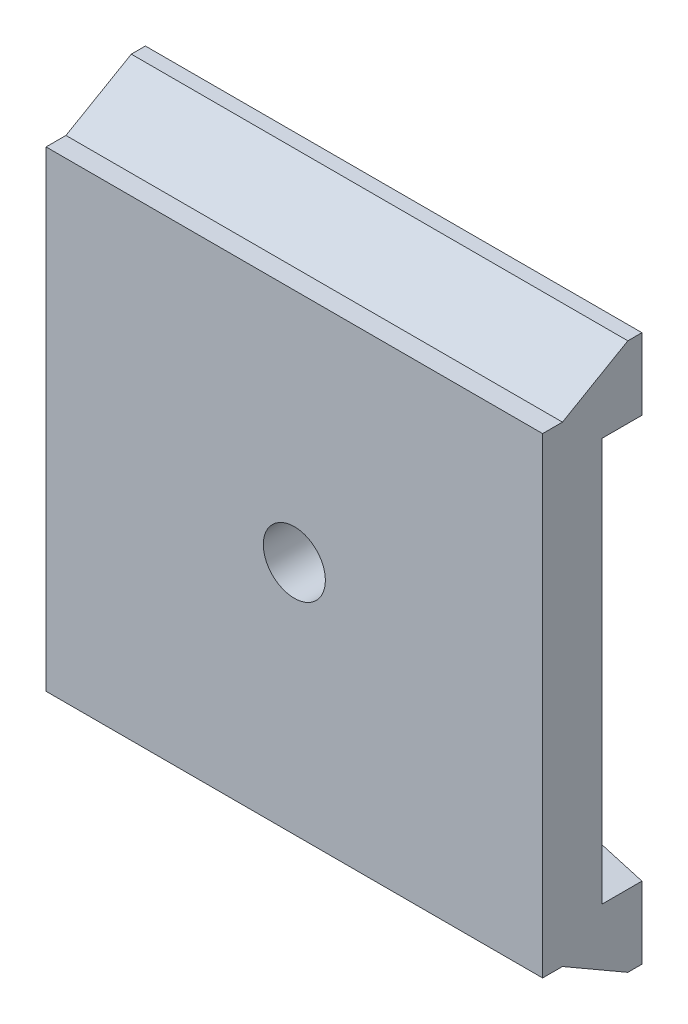
from build123d import *

# Parameters (mm, degrees)
SKETCH1_W           = 50.8
SKETCH1_H           = 55.9562
BOSS_EXTRUDE1_DEPTH = 10.16
SKETCH2_W           = 50.8
SKETCH2_H           = 3.8608
CUT_EXTRUDE1_DEPTH  = 2.032
CUT_EXTRUDE2_DEPTH  = 51.8
SKETCH4_R           = 3.175
CUT_EXTRUDE3_DEPTH  = 11.16
SKETCH5_W           = 50.8
SKETCH5_H           = 33.9852
CUT_EXTRUDE4_DEPTH  = 4.064
CUT_EXTRUDE5_DEPTH  = 4.064
CUT_EXTRUDE6_DEPTH  = 4.064


with BuildPart() as part:
    # Sketch1 → Boss-Extrude1 (new body)
    with BuildSketch(Plane.XY):
        Rectangle(SKETCH1_W, SKETCH1_H)
    extrude(amount=BOSS_EXTRUDE1_DEPTH)

    # Sketch2 → Cut-Extrude1 (cut)
    with BuildSketch(Plane.XY.offset(10.16)):
        with Locations((0, 26.0477)):
            Rectangle(SKETCH2_W, SKETCH2_H)
        with Locations((0, -26.0477)):
            Rectangle(SKETCH2_W, SKETCH2_H)
    extrude(amount=-CUT_EXTRUDE1_DEPTH, mode=Mode.SUBTRACT)

    # Sketch3 → Cut-Extrude2 (cut, through all)
    with BuildSketch(Plane.ZY.offset(25.4)):
        Polygon((8.128, 24.1173), (1.440898242, 27.9781), (8.128, 27.9781), align=None)
        Polygon((8.128, -24.1173), (1.440898242, -27.9781), (8.128, -27.9781), align=None)
    extrude(amount=-CUT_EXTRUDE2_DEPTH, mode=Mode.SUBTRACT)

    # Sketch4 → Cut-Extrude3 (cut, through all)
    with BuildSketch(Plane.XY.offset(10.16)):
        Circle(SKETCH4_R)
    extrude(amount=-CUT_EXTRUDE3_DEPTH, mode=Mode.SUBTRACT)

    # Sketch5 → Cut-Extrude4 (cut)
    with BuildSketch(Plane(origin=(0, 0, 0), x_dir=(-1, 0, 0), z_dir=(0, 0, -1))):
        Rectangle(SKETCH5_W, SKETCH5_H)
    extrude(amount=-CUT_EXTRUDE4_DEPTH, mode=Mode.SUBTRACT)

    # Sketch6 → Cut-Extrude5 (cut)
    with BuildSketch(Plane(origin=(0, 0, 0), x_dir=(-1, 0, 0), z_dir=(0, 0, -1))):
        with BuildLine():
            Line((6.35, 21.0058), (-6.35, 21.0058))
            ThreePointArc((-6.35, 21.0058), (-8.59506403, 20.07586403), (-9.525, 17.8308))
            Line((-9.525, 17.8308), (-9.525, -17.8308))
            ThreePointArc((-9.525, -17.8308), (-8.59506403, -20.07586403), (-6.35, -21.0058))
            Line((-6.35, -21.0058), (6.35, -21.0058))
            ThreePointArc((6.35, -21.0058), (8.59506403, -20.07586403), (9.525, -17.8308))
            Line((9.525, -17.8308), (9.525, 17.8308))
            ThreePointArc((9.525, 17.8308), (8.59506403, 20.07586403), (6.35, 21.0058))
        make_face()
    extrude(amount=-CUT_EXTRUDE5_DEPTH, mode=Mode.SUBTRACT)

    # Sketch7 → Cut-Extrude6 (cut)
    with BuildSketch(Plane(origin=(0, 0, 0), x_dir=(-1, 0, 0), z_dir=(0, 0, -1))):
        Polygon((-12.7, 16.9926), (-25.4, 20.658774209), (-25.4, 16.9926), align=None)
        Polygon((-12.861684204, -16.9926), (-25.4, -20.6121), (-25.4, -16.9926), align=None)
        Polygon((12.7, -16.9926), (25.4, -20.658774209), (25.4, -16.9926), align=None)
        Polygon((12.7, 16.9926), (25.4, 20.658774209), (25.4, 16.9926), align=None)
    extrude(amount=-CUT_EXTRUDE6_DEPTH, mode=Mode.SUBTRACT)


solid = part.part
